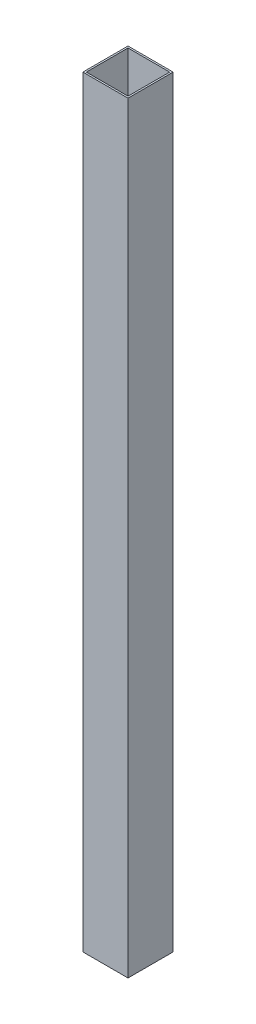
from build123d import *

# Parameters (mm, degrees)
SKETCH1_W           = 25.4
SKETCH1_H           = 25.4
SKETCH1_W_2         = 23.4696
SKETCH1_H_2         = 23.4696
BOSS_EXTRUDE1_DEPTH = 428.625


with BuildPart() as part:
    # Sketch1 → Boss-Extrude1 (new body)
    with BuildSketch(Plane(origin=(0, 0, 0), x_dir=(1, 0, 0), z_dir=(0, 1, 0))):
        Rectangle(SKETCH1_W, SKETCH1_H)
        Rectangle(SKETCH1_W_2, SKETCH1_H_2, mode=Mode.SUBTRACT)
    extrude(amount=BOSS_EXTRUDE1_DEPTH)


solid = part.part
